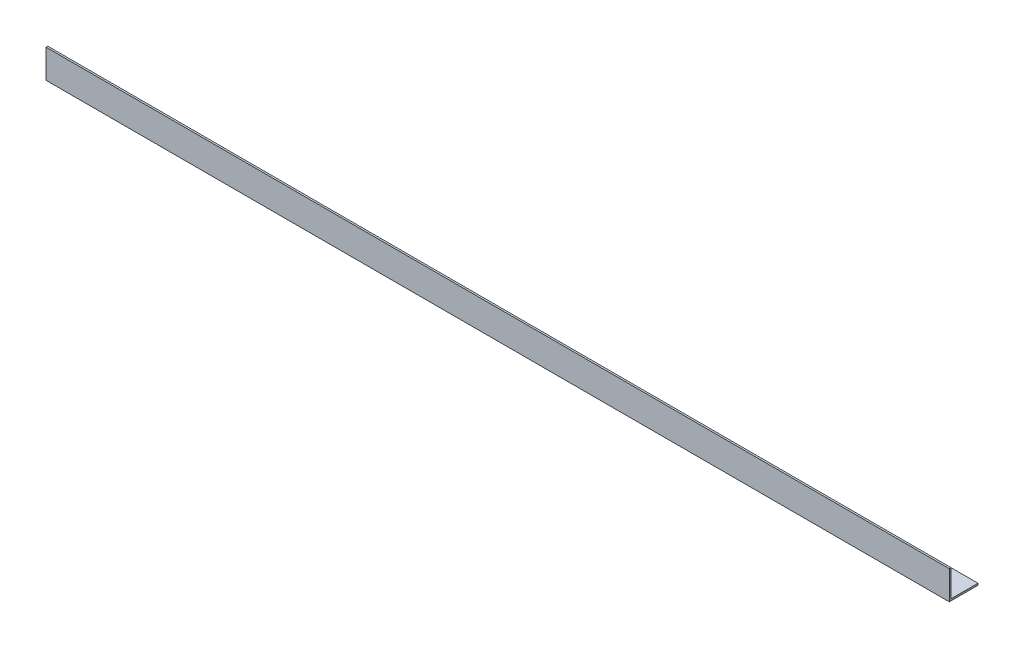
from build123d import *

# Parameters (mm, degrees)
BOSS_EXTRUDE1_DEPTH = 800.1


with BuildPart() as part:
    # Sketch4 → Boss-Extrude1 (new body)
    with BuildSketch(Plane(origin=(0, 0, 0), x_dir=(0, 0, -1), z_dir=(1, 0, 0))):
        Polygon((0, 0), (0, 25.4), (1.5875, 25.4), (1.5875, 1.5875), (25.4, 1.5875), (25.4, 0), align=None)
    extrude(amount=BOSS_EXTRUDE1_DEPTH)


solid = part.part
